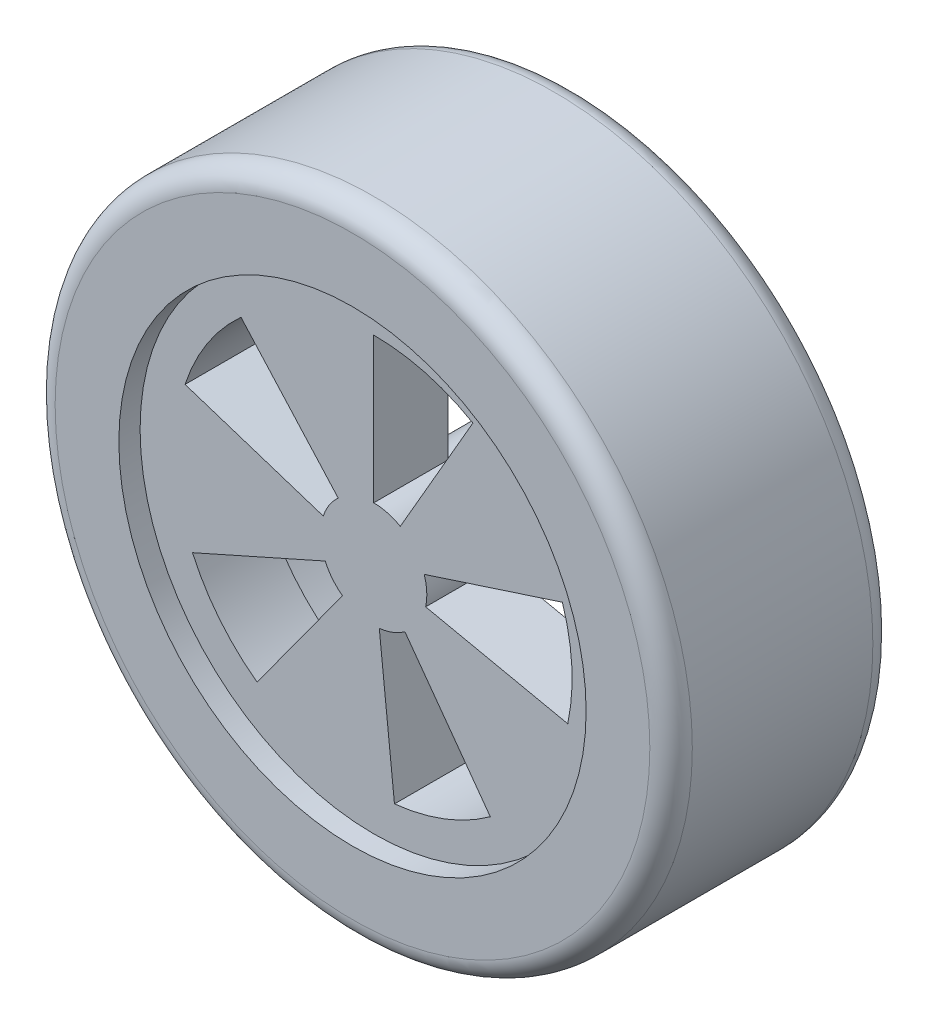
from build123d import *
from build123d.topology import SkipClean

# Parameters (mm, degrees)
SKETCH1_R           = 15
BOSS_EXTRUDE1_DEPTH = 10.5
SKETCH2_R           = 11
CUT_EXTRUDE1_DEPTH  = 1
SKETCH3_R           = 12
SKETCH3_R_2         = 2.5
SKETCH3_R_3         = 1
CUT_EXTRUDE2_DEPTH  = 6
BOSS_EXTRUDE2_START = 2.5
SKETCH3_4_R         = 2.5
SKETCH3_4_R_2       = 1
BOSS_EXTRUDE2_DEPTH = 2.5
FILLET1_R           = 1
CUT_EXTRUDE3_DEPTH  = 25.372115214


with BuildPart() as part:
    # Sketch1 → Boss-Extrude1 (new body)
    with BuildSketch(Plane.XY):
        Circle(SKETCH1_R)
    extrude(amount=BOSS_EXTRUDE1_DEPTH)

    # Sketch2 → Cut-Extrude1 (cut)
    with BuildSketch(Plane.XY.offset(10.5)):
        Circle(SKETCH2_R)
    extrude(amount=-CUT_EXTRUDE1_DEPTH, mode=Mode.SUBTRACT)

    # Sketch3 → Cut-Extrude2 (cut)
    # profile 1 of 2: a face of its own
    with BuildSketch(Plane(origin=(0, 0, 0), x_dir=(-1, 0, 0), z_dir=(0, 0, -1))):
        Circle(SKETCH3_R)
        Circle(SKETCH3_R_2, mode=Mode.SUBTRACT)
    # profile 2 of 2: a face of its own
    with BuildSketch(Plane(origin=(0, 0, 0), x_dir=(-1, 0, 0), z_dir=(0, 0, -1))):
        Circle(SKETCH3_R_3)
    extrude(amount=-CUT_EXTRUDE2_DEPTH, mode=Mode.SUBTRACT)

    # Sketch3_4 → Boss-Extrude2 (add)
    with BuildSketch(Plane(origin=(0, 0, 0), x_dir=(-1, 0, 0), z_dir=(0, 0, -1)).offset(BOSS_EXTRUDE2_START)):
        Circle(SKETCH3_4_R)
        Circle(SKETCH3_4_R_2, mode=Mode.SUBTRACT)
    extrude(amount=-BOSS_EXTRUDE2_DEPTH)

    # Fillet1
    fillet1_edges = [part.edges().sort_by_distance(p)[0] for p in [
        (-15, 0, 0),
        (-15, 0, 10.5),
    ]]
    fillet(fillet1_edges, radius=FILLET1_R)

    # Sketch4 → Cut-Extrude3 (cut, through all)
    with SkipClean():  # the faces are left unmerged after this step: merging them gives an invalid solid
        with BuildSketch(Plane.XY.offset(9.5)):
            with BuildLine():
                Line((0, 2.5), (0, 9.339610027))
                ThreePointArc((0, 9.339610027), (2.417268949, 9.021370532), (4.669805013, 8.088339545))
                Line((4.669805013, 8.088339545), (1.25, 2.165063509))
                ThreePointArc((1.25, 2.165063509), (0.647047613, 2.414814566), (0, 2.5))
            make_face()
            with BuildLine():
                Line((2.377641291, 0.772542486), (8.882496976, 2.886098219))
                ThreePointArc((8.882496976, 2.886098219), (9.326810416, 0.488797422), (9.135517139, -1.941814112))
                Line((9.135517139, -1.941814112), (2.445369002, -0.519779227))
                ThreePointArc((2.445369002, -0.519779227), (2.496573837, 0.130839891), (2.377641291, 0.772542486))
            make_face()
            with BuildLine():
                Line((1.469463131, -2.022542486), (5.489685036, -7.555903232))
                ThreePointArc((5.489685036, -7.555903232), (3.347016895, -8.719277112), (0.976255084, -9.288446666))
                Line((0.976255084, -9.288446666), (0.261321158, -2.486304738))
                ThreePointArc((0.261321158, -2.486304738), (0.895919874, -2.333951066), (1.469463131, -2.022542486))
            make_face()
            with BuildLine():
                Line((-1.469463131, -2.022542486), (-5.489685036, -7.555903232))
                ThreePointArc((-5.489685036, -7.555903232), (-7.258240214, -5.877607034), (-8.532158316, -3.79876163))
                Line((-8.532158316, -3.79876163), (-2.283863644, -1.016841608))
                ThreePointArc((-2.283863644, -1.016841608), (-1.942864904, -1.573300978), (-1.469463131, -2.022542486))
            make_face()
            with BuildLine():
                Line((-2.377641291, 0.772542486), (-8.882496976, 2.886098219))
                ThreePointArc((-8.882496976, 2.886098219), (-7.832856045, 5.086716192), (-6.24941892, 6.940682863))
                Line((-6.24941892, 6.940682863), (-1.672826516, 1.857862064))
                ThreePointArc((-1.672826516, 1.857862064), (-2.09667642, 1.361597588), (-2.377641291, 0.772542486))
            make_face()
        extrude(amount=-CUT_EXTRUDE3_DEPTH, mode=Mode.SUBTRACT)


solid = part.part
